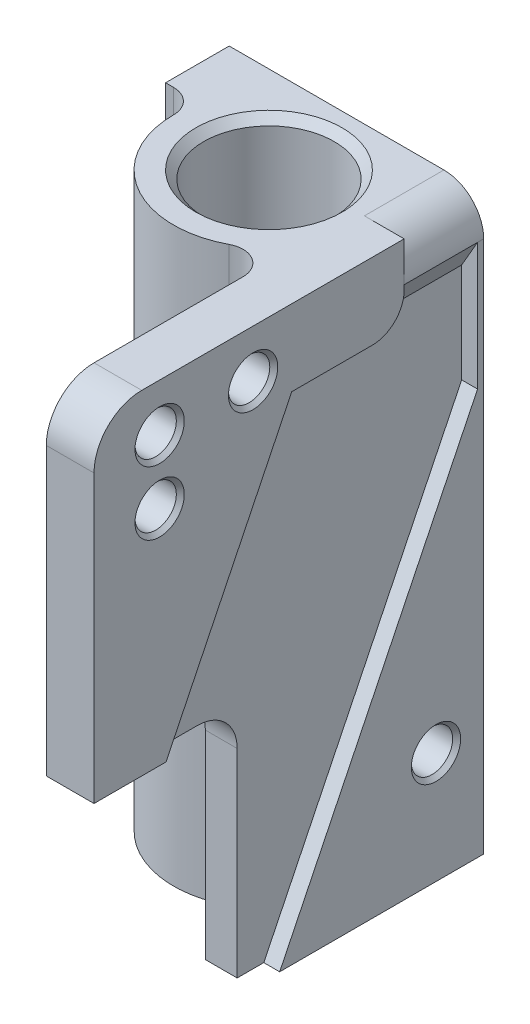
from build123d import *

# Parameters (mm, degrees)
SKETCH1_R               = 8.2
BOSS_EXTRUDE1_DEPTH     = 72
SKETCH2_R               = 2.6
CUT_EXTRUDE1_DEPTH      = 6
CHAMFER1_SIZE           = 0.5
CHAMFER2_SIZE           = 1
SKETCH3_R               = 2.6
CUT_EXTRUDE2_DEPTH      = 33
CUT_EXTRUDE3_DEPTH      = 10
CUT_EXTRUDE4_DEPTH      = 2
CUT_EXTRUDE5_DEPTH      = 10
CUT_EXTRUDE5_DEPTH_BACK = 10
CUT_EXTRUDE6_DEPTH      = 9.232013
FILLET1_R               = 4
FILLET2_R               = 6
SKETCH9_R               = 2.6
CUT_EXTRUDE7_DEPTH      = 6
CHAMFER3_SIZE           = 0.5


with BuildPart() as part:
    # Sketch1 → Boss-Extrude1 (new body)
    with BuildSketch(Plane(origin=(0, 0, 0), x_dir=(1, 0, 0), z_dir=(0, 1, 0))):
        with BuildLine():
            Line((-16, 11), (16, 11))
            Line((16, 11), (16, -38))
            Line((16, -38), (10, -38))
            Line((10, -38), (10, -13.266499161))
            ThreePointArc((10, -13.266499161), (8.549193338, -10.697452646), (5.6, -10.613199329))
            ThreePointArc((5.6, -10.613199329), (-6.196773354, -10.276186063), (-12, 0))
            ThreePointArc((-12, 0), (-12.878679656, 2.121320344), (-15, 3))
            Line((-15, 3), (-16, 3))
            Line((-16, 3), (-16, 11))
        make_face()
        with Locations(Location((0, 0, 0), (0, 0, 270))):  # turned: the seam where the file's is
            Circle(SKETCH1_R, mode=Mode.SUBTRACT)
    extrude(amount=BOSS_EXTRUDE1_DEPTH)

    # Sketch2 → Cut-Extrude1 (cut)
    with BuildSketch(Plane.XY.offset(-11)):
        with Locations((-11, 67)):
            Circle(SKETCH2_R)
        with Locations((-11, 5)):
            Circle(SKETCH2_R)
        with Locations((11, 67)):
            Circle(SKETCH2_R)
        with Locations((11, 5)):
            Circle(SKETCH2_R)
    extrude(amount=CUT_EXTRUDE1_DEPTH, mode=Mode.SUBTRACT)

    # Chamfer1
    chamfer1_edges = [part.edges().sort_by_distance(p)[0] for p in [
        (-13.6, 67, -11),
        (-13.6, 5, -11),
        (8.4, 67, -11),
        (8.4, 5, -11),
    ]]
    chamfer(chamfer1_edges, length=CHAMFER1_SIZE)

    # Chamfer2
    chamfer2_edges = [part.edges().sort_by_distance(p)[0] for p in [
        (0, 0, -8.2),
        (0, 72, -8.2),
    ]]
    chamfer(chamfer2_edges, length=CHAMFER2_SIZE)

    # Sketch3 → Cut-Extrude2 (cut, through all)
    with BuildSketch(Plane(origin=(16, 0, 0), x_dir=(0, 0, -1), z_dir=(1, 0, 0))):
        with Locations((-29.75, 66)):
            Circle(SKETCH3_R)
        with Locations((-29.75, 58)):
            Circle(SKETCH3_R)
    extrude(amount=-CUT_EXTRUDE2_DEPTH, mode=Mode.SUBTRACT)

    # Sketch4 → Cut-Extrude3 (cut)
    with BuildSketch(Plane(origin=(0, 0, -11), x_dir=(-1, 0, 0), z_dir=(0, 0, -1))):
        with BuildLine():
            Line((-11, 72), (-16, 72))
            Line((-16, 72), (-16, 67))
            ThreePointArc((-16, 67), (-14.535533906, 70.535533906), (-11, 72))
        make_face()
    extrude(amount=-CUT_EXTRUDE3_DEPTH, mode=Mode.SUBTRACT)

    # Sketch5 → Cut-Extrude4 (cut)
    with BuildSketch(Plane(origin=(16, 0, 0), x_dir=(0, 0, -1), z_dir=(1, 0, 0))):
        Polygon((10.232013106, 51.021676305), (-14.652921151, 0), (-38, 0), (-38, 11.441867396), (-13.136632097, 62.419326121), (10.232013106, 62.419326121), align=None)
    extrude(amount=-CUT_EXTRUDE4_DEPTH, mode=Mode.SUBTRACT)

    # Sketch6 → Cut-Extrude5 (cut, two sides)
    with BuildSketch(Plane(origin=(14, 0, 0), x_dir=(0, 0, -1), z_dir=(1, 0, 0))) as cut_extrude5_sk:
        with BuildLine():
            Line((-38, 0), (-18, 0))
            Line((-18, 0), (-18, 25))
            ThreePointArc((-18, 25), (-19.464466094, 28.535533906), (-23, 30))
            Line((-23, 30), (-38, 30))
            Line((-38, 30), (-38, 0))
        make_face()
    extrude(amount=CUT_EXTRUDE5_DEPTH, mode=Mode.SUBTRACT)
    extrude(cut_extrude5_sk.sketch, amount=-CUT_EXTRUDE5_DEPTH_BACK, mode=Mode.SUBTRACT)

    # Sketch8 → Cut-Extrude6 (cut)
    with BuildSketch(Plane(origin=(0, 0, -1), x_dir=(-1, 0, 0), z_dir=(0, 0, -1))):
        Polygon((-16, 67), (-16, 62.419326121), (-14, 62.419326121), (-14, 63.535898385), align=None)
    extrude(amount=CUT_EXTRUDE6_DEPTH, mode=Mode.SUBTRACT)

    # Fillet1
    fillet1_edges = [part.edges().sort_by_distance(p)[0] for p in [
        (15, 62.419326121, -1),
    ]]
    fillet(fillet1_edges, radius=FILLET1_R)

    # Fillet2
    fillet2_edges = [part.edges().sort_by_distance(p)[0] for p in [
        (13, 72, 38),
    ]]
    fillet(fillet2_edges, radius=FILLET2_R)

    # Sketch9 → Cut-Extrude7 (cut)
    with BuildSketch(Plane(origin=(16, 0, 0), x_dir=(0, 0, -1), z_dir=(1, 0, 0))):
        with Locations((-18, 66)):
            Circle(SKETCH9_R)
        with Locations((5, 14)):
            Circle(SKETCH9_R)
    extrude(amount=-CUT_EXTRUDE7_DEPTH, mode=Mode.SUBTRACT)

    # Chamfer3
    chamfer3_edges = [part.edges().sort_by_distance(p)[0] for p in [
        (16, 66, 20.6),
        (16, 14, -2.4),
        (16, 66, 32.35),
        (16, 58, 32.35),
    ]]
    chamfer(chamfer3_edges, length=CHAMFER3_SIZE)


solid = part.part
